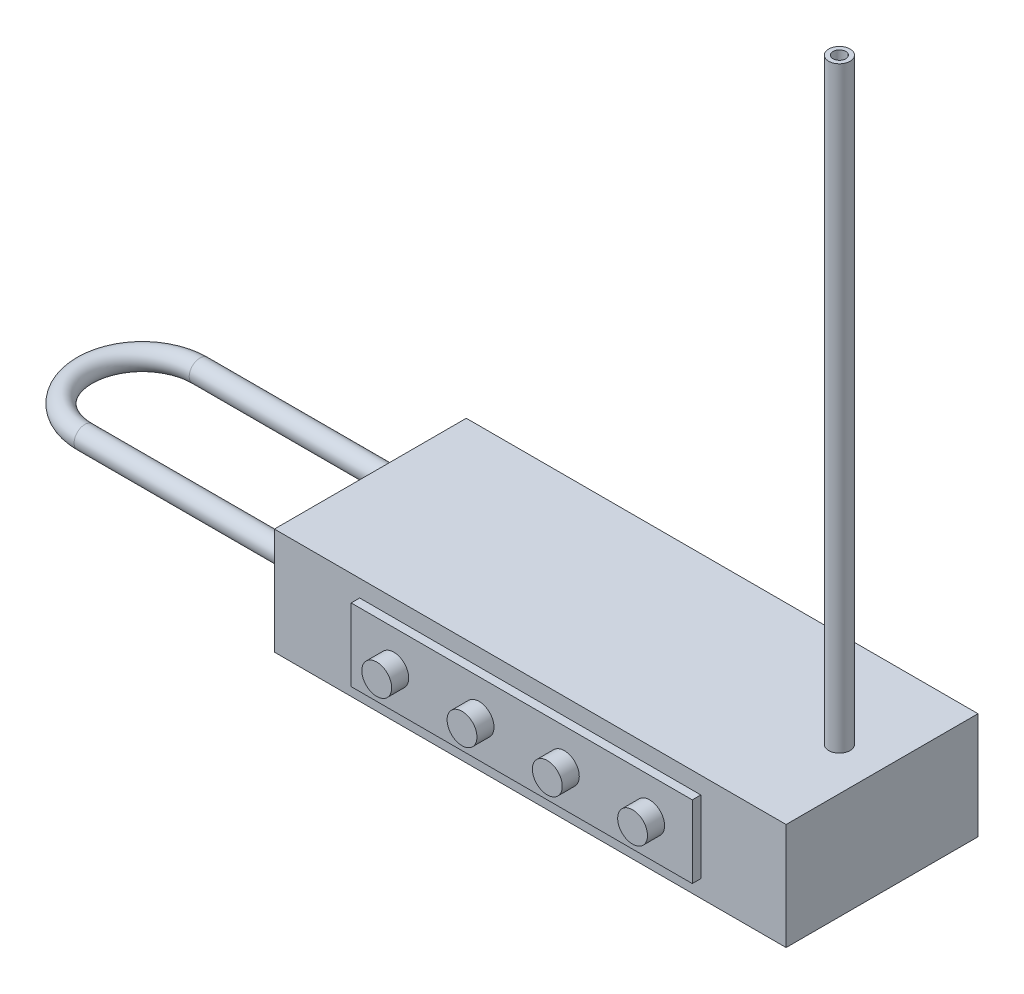
from build123d import *

# Parameters (mm, degrees)
SKETCH1_W               = 120
SKETCH1_H               = 45
BOSS_EXTRUDE1_DEPTH     = 12.5
SKETCH3_R               = 2.5
SKETCH3_R_2             = 1.5
BOSS_EXTRUDE2_DEPTH     = 140
SWEEP_THIN2_PROFILE_R   = 2.5
SWEEP_THIN2_PROFILE_R_2 = 1.5
SKETCH53_W              = 80
SKETCH53_H              = 17
BOSS_EXTRUDE3_DEPTH     = 2
SKETCH54_R              = 3.5
BOSS_EXTRUDE4_DEPTH     = 4
LPATTERN1_COUNT         = 2
LPATTERN1_PITCH         = 20
LPATTERN1_COL_COUNT     = 3
LPATTERN1_COL_PITCH     = 20


with BuildPart() as part:
    # Sketch1 → Boss-Extrude1 (new, symmetric)
    with BuildSketch(Plane(origin=(0, 0, 0), x_dir=(1, 0, 0), z_dir=(0, 1, 0))):
        Rectangle(SKETCH1_W, SKETCH1_H)
    extrude(amount=BOSS_EXTRUDE1_DEPTH, both=True)

    # Sketch3 → Boss-Extrude2 (add)
    with BuildSketch(Plane(origin=(0, 12.5, 0), x_dir=(1, 0, 0), z_dir=(0, 1, 0))):
        with Locations((50, 0)):
            Circle(SKETCH3_R)
        with Locations((50, 0)):
            Circle(SKETCH3_R_2, mode=Mode.SUBTRACT)
    extrude(amount=BOSS_EXTRUDE2_DEPTH)

    # Sweep-Thin2: sweep along a path in Sketch57
    with BuildLine(Plane(origin=(0, 0, 0), x_dir=(1, 0, 0), z_dir=(0, 1, 0))) as sweep_thin2_path:
        Line((-60, 13.5), (-113.472065941, 13.5))
        ThreePointArc((-113.472065941, 13.5), (-126.972065941, 0), (-113.472065941, -13.5))
        Line((-113.472065941, -13.5), (-60, -13.5))
    # Sweep-Thin2 profile (on start of the path) → Sweep-Thin2 (sweep)
    with BuildSketch(Plane(origin=(-60, 0, -13.5), x_dir=(0, 0, -1), z_dir=(-1, 0, 0))):
        Circle(SWEEP_THIN2_PROFILE_R)
        Circle(SWEEP_THIN2_PROFILE_R_2, mode=Mode.SUBTRACT)
    sweep(path=sweep_thin2_path.line)

    # Sketch53 → Boss-Extrude3 (add)
    with BuildSketch(Plane.XY.offset(22.5)):
        Rectangle(SKETCH53_W, SKETCH53_H)
    extrude(amount=BOSS_EXTRUDE3_DEPTH)

    # Sketch54 → Boss-Extrude4 (add)
    with BuildSketch(Plane.XY.offset(24.5)):
        with Locations((-10, 0)):
            Circle(SKETCH54_R)
    boss_extrude4 = extrude(amount=BOSS_EXTRUDE4_DEPTH)

    # LPattern1: Boss-Extrude4 ×2
    with Locations(*[(-i * LPATTERN1_PITCH, 0, 0) for i in range(1, LPATTERN1_COUNT)]):
        add(boss_extrude4)

    # LPattern1 col: Boss-Extrude4 ×3
    with Locations(*[(i * LPATTERN1_COL_PITCH, 0, 0) for i in range(1, LPATTERN1_COL_COUNT)]):
        add(boss_extrude4)


solid = part.part
